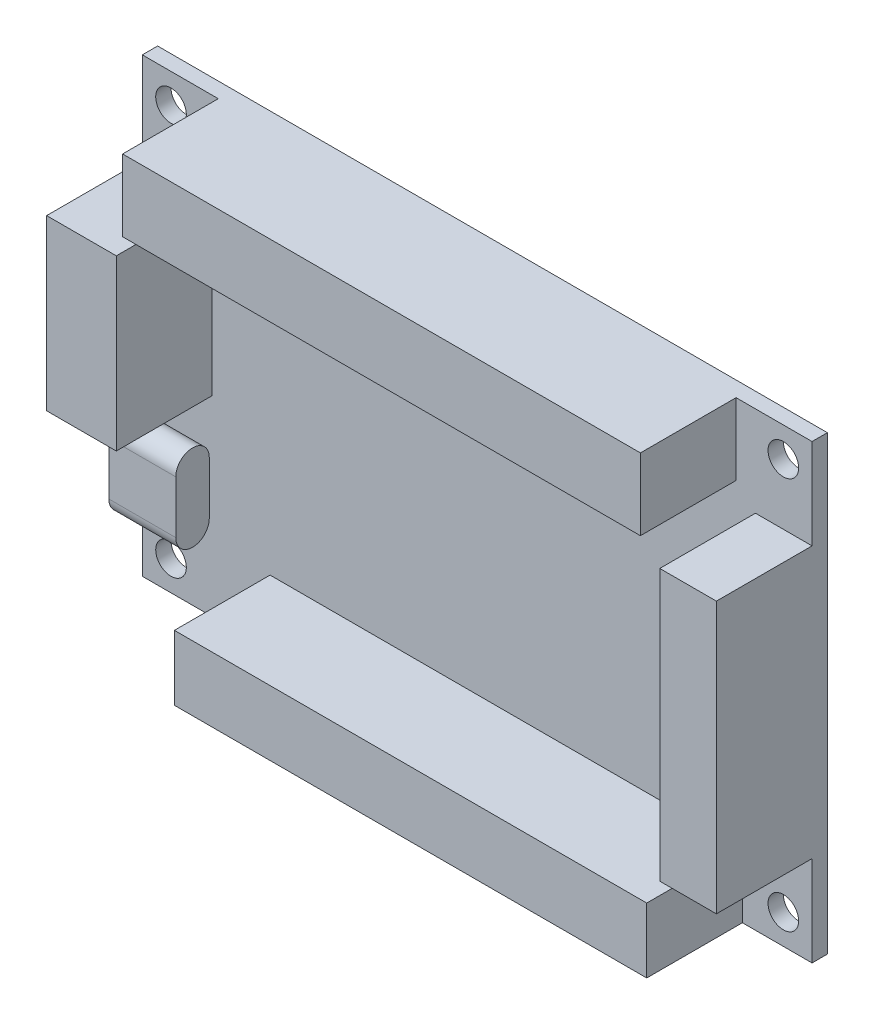
from build123d import *

# Parameters (mm, degrees)
ESBO_O1_W                = 70
ESBO_O1_H                = 47.2
ESBO_O1_R                = 1.6
RESSALTO_EXTRUS_O1_DEPTH = 1.6
ESBO_O2_W                = 49.366448858
ESBO_O2_H                = 6.785766069
ESBO_O2_W_2              = 54.120377738
ESBO_O2_H_2              = 7.496391297
ESBO_O2_W_3              = 5.916216247
ESBO_O2_H_3              = 28.306864236
ESBO_O2_W_4              = 7.279806524
ESBO_O2_H_4              = 17.669935009
RESSALTO_EXTRUS_O2_DEPTH = 10
RESSALTO_EXTRUS_O3_DEPTH = 7


with BuildPart() as part:
    # Esboço1 → Ressalto-extrusão1 (new body)
    with BuildSketch(Plane.XY):
        Rectangle(ESBO_O1_W, ESBO_O1_H)
        with Locations((-32, 20.5)):
            Circle(ESBO_O1_R, mode=Mode.SUBTRACT)
        with Locations((32, 20.5)):
            Circle(ESBO_O1_R, mode=Mode.SUBTRACT)
        with Locations((32, -20.5)):
            Circle(ESBO_O1_R, mode=Mode.SUBTRACT)
        with Locations((-32, -20.5)):
            Circle(ESBO_O1_R, mode=Mode.SUBTRACT)
    extrude(amount=RESSALTO_EXTRUS_O1_DEPTH)

    # Esboço2 → Ressalto-extrusão2 (add)
    with BuildSketch(Plane.XY.offset(1.6)):
        with Locations((3.036969047, -20.207116965)):
            Rectangle(ESBO_O2_W, ESBO_O2_H)
        with Locations((0, 19.851804352)):
            Rectangle(ESBO_O2_W_2, ESBO_O2_H_2)
        with Locations((32.041891877, 0)):
            Rectangle(ESBO_O2_W_3, ESBO_O2_H_3)
        with Locations((-31.360096738, 5.213703653)):
            Rectangle(ESBO_O2_W_4, ESBO_O2_H_4)
    extrude(amount=RESSALTO_EXTRUS_O2_DEPTH)

    # Esboço3 → Ressalto-extrusão3 (add)
    with BuildSketch(Plane.ZY.offset(35)):
        with BuildLine():
            Line((5.1, -9.35), (5.1, -14.85))
            ThreePointArc((5.1, -14.85), (3.35, -16.6), (1.6, -14.85))
            Line((1.6, -14.85), (1.6, -9.35))
            ThreePointArc((1.6, -9.35), (3.35, -7.6), (5.1, -9.35))
        make_face()
    extrude(amount=-RESSALTO_EXTRUS_O3_DEPTH)


solid = part.part
